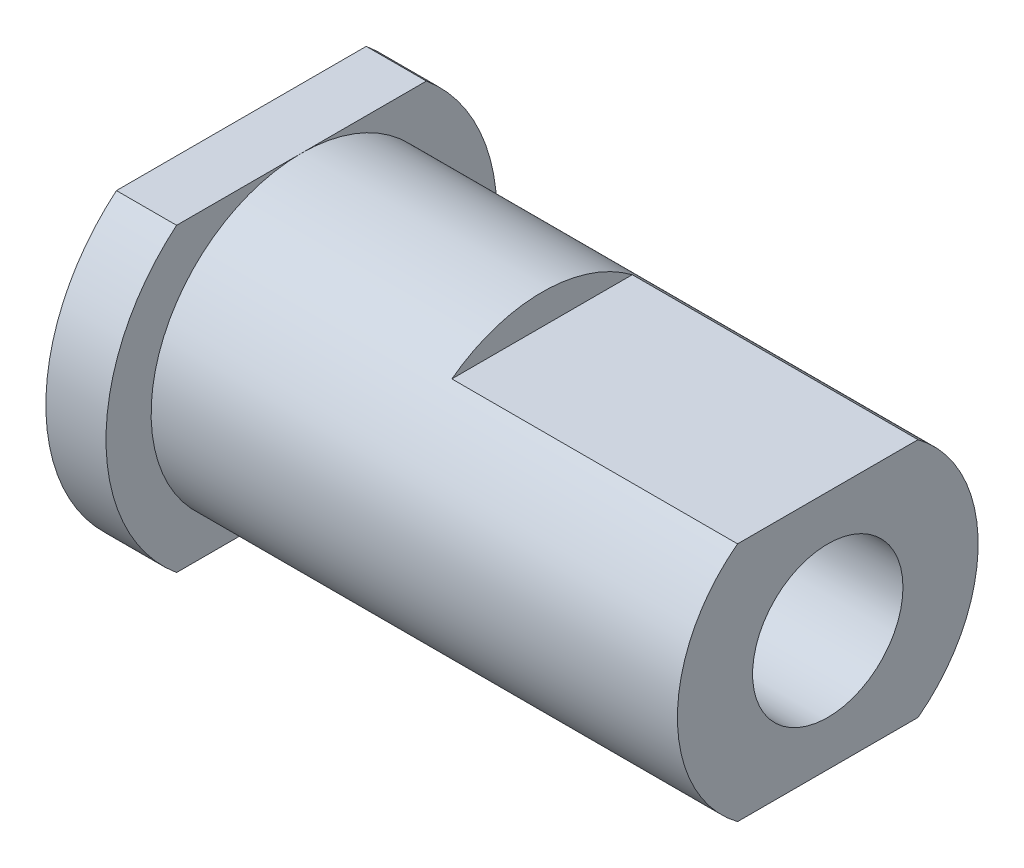
from build123d import *

# Parameters (mm, degrees)
SKETCH1_W           = 8.306623862
SKETCH1_H           = 10
BOSS_EXTRUDE1_DEPTH = 2
SKETCH2_R           = 5
BOSS_EXTRUDE2_DEPTH = 8
SKETCH3_W           = 6
SKETCH3_H           = 8
BOSS_EXTRUDE3_DEPTH = 9.5
SKETCH4_R           = 2.5
CUT_EXTRUDE1_DEPTH  = 20.5


with BuildPart() as part:
    # Sketch1 → Boss-Extrude1 (new body)
    with BuildSketch(Plane(origin=(0, 0, 0), x_dir=(0, 0, -1), z_dir=(1, 0, 0))):
        with BuildLine():
            Line((-4.153311931, -5), (-4.153311931, 5))
            ThreePointArc((-4.153311931, 5), (-6.5, 0), (-4.153311931, -5))
        make_face()
        Rectangle(SKETCH1_W, SKETCH1_H)
        with BuildLine():
            Line((4.153311931, -5), (4.153311931, 5))
            ThreePointArc((4.153311931, 5), (6.5, 0), (4.153311931, -5))
        make_face()
    extrude(amount=BOSS_EXTRUDE1_DEPTH)

    # Sketch2 → Boss-Extrude2 (add)
    with BuildSketch(Plane(origin=(2, 0, 0), x_dir=(0, 0, -1), z_dir=(1, 0, 0))):
        Circle(SKETCH2_R)
    extrude(amount=BOSS_EXTRUDE2_DEPTH)

    # Sketch3 → Boss-Extrude3 (add)
    with BuildSketch(Plane(origin=(10, 0, 0), x_dir=(0, 0, -1), z_dir=(1, 0, 0))):
        with BuildLine():
            ThreePointArc((-3, 4), (-5, 0), (-3, -4))
            Line((-3, -4), (-3, 4))
        make_face()
        Rectangle(SKETCH3_W, SKETCH3_H)
        with BuildLine():
            Line((3, 4), (3, -4))
            ThreePointArc((3, -4), (4.472135955, -2.236067977), (5, 0))
            ThreePointArc((5, 0), (4.472135955, 2.236067977), (3, 4))
        make_face()
    extrude(amount=BOSS_EXTRUDE3_DEPTH)

    # Sketch4 → Cut-Extrude1 (cut, through all)
    with BuildSketch(Plane(origin=(19.5, 0, 0), x_dir=(0, 0, -1), z_dir=(1, 0, 0))):
        Circle(SKETCH4_R)
    extrude(amount=-CUT_EXTRUDE1_DEPTH, mode=Mode.SUBTRACT)


solid = part.part
